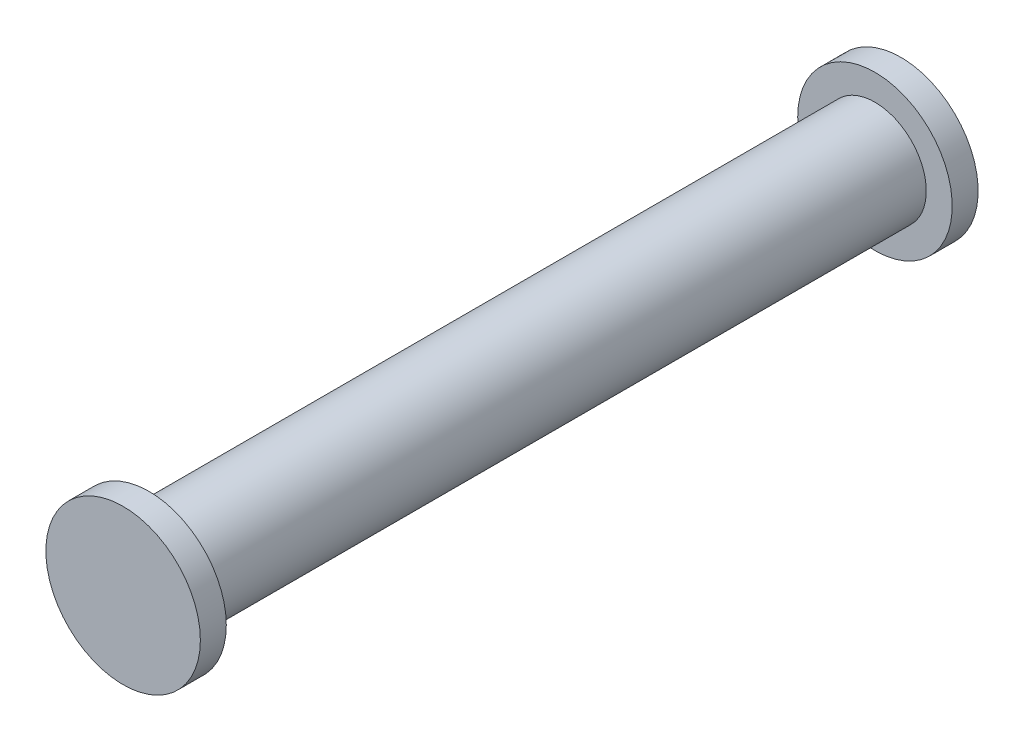
from build123d import *

# Parameters (mm, degrees)
SKETCH1_R           = 4.95
BOSS_EXTRUDE1_DEPTH = 70
SKETCH2_R           = 7.45
BOSS_EXTRUDE2_DEPTH = 2.5
SKETCH3_R           = 7.45
BOSS_EXTRUDE3_DEPTH = 2.5


with BuildPart() as part:
    # Sketch1 → Boss-Extrude1 (new body)
    with BuildSketch(Plane.XY):
        Circle(SKETCH1_R)
    extrude(amount=BOSS_EXTRUDE1_DEPTH)

    # Sketch2 → Boss-Extrude2 (add)
    with BuildSketch(Plane(origin=(0, 0, 0), x_dir=(-1, 0, 0), z_dir=(0, 0, -1))):
        Circle(SKETCH2_R)
    extrude(amount=BOSS_EXTRUDE2_DEPTH)

    # Sketch3 → Boss-Extrude3 (add)
    with BuildSketch(Plane.XY.offset(70)):
        Circle(SKETCH3_R)
    extrude(amount=BOSS_EXTRUDE3_DEPTH)


solid = part.part
